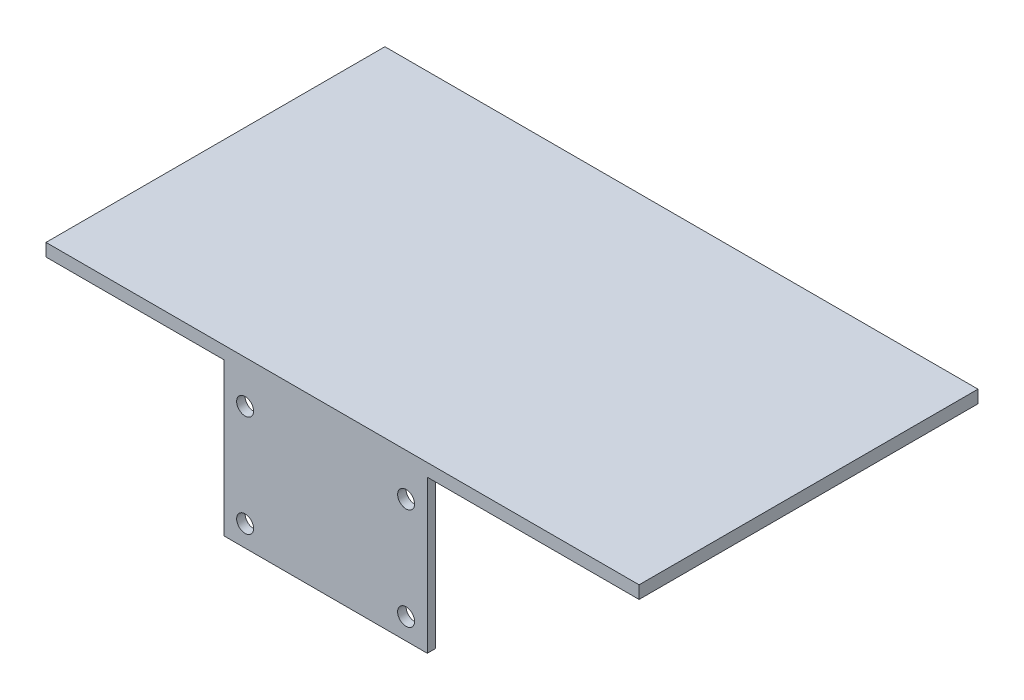
from build123d import *

# Parameters (mm, degrees)
SKETCH1_W           = 48
SKETCH1_H           = 36
SKETCH1_R           = 2
BOSS_EXTRUDE1_DEPTH = 2
SKETCH2_W           = 140
SKETCH2_H           = 80
BOSS_EXTRUDE2_DEPTH = 3


with BuildPart() as part:
    # Sketch1 → Boss-Extrude1 (new body)
    with BuildSketch(Plane.XY):
        Rectangle(SKETCH1_W, SKETCH1_H)
        with Locations((-19, 11)):
            Circle(SKETCH1_R, mode=Mode.SUBTRACT)
        with Locations((-19, -13)):
            Circle(SKETCH1_R, mode=Mode.SUBTRACT)
        with Locations((19, -13)):
            Circle(SKETCH1_R, mode=Mode.SUBTRACT)
        with Locations((19, 11)):
            Circle(SKETCH1_R, mode=Mode.SUBTRACT)
    extrude(amount=BOSS_EXTRUDE1_DEPTH)

    # Sketch2 → Boss-Extrude2 (add)
    with BuildSketch(Plane(origin=(0, 18, 0), x_dir=(1, 0, 0), z_dir=(0, 1, 0))):
        with Locations((4, 38)):
            Rectangle(SKETCH2_W, SKETCH2_H)
    extrude(amount=BOSS_EXTRUDE2_DEPTH)


solid = part.part
